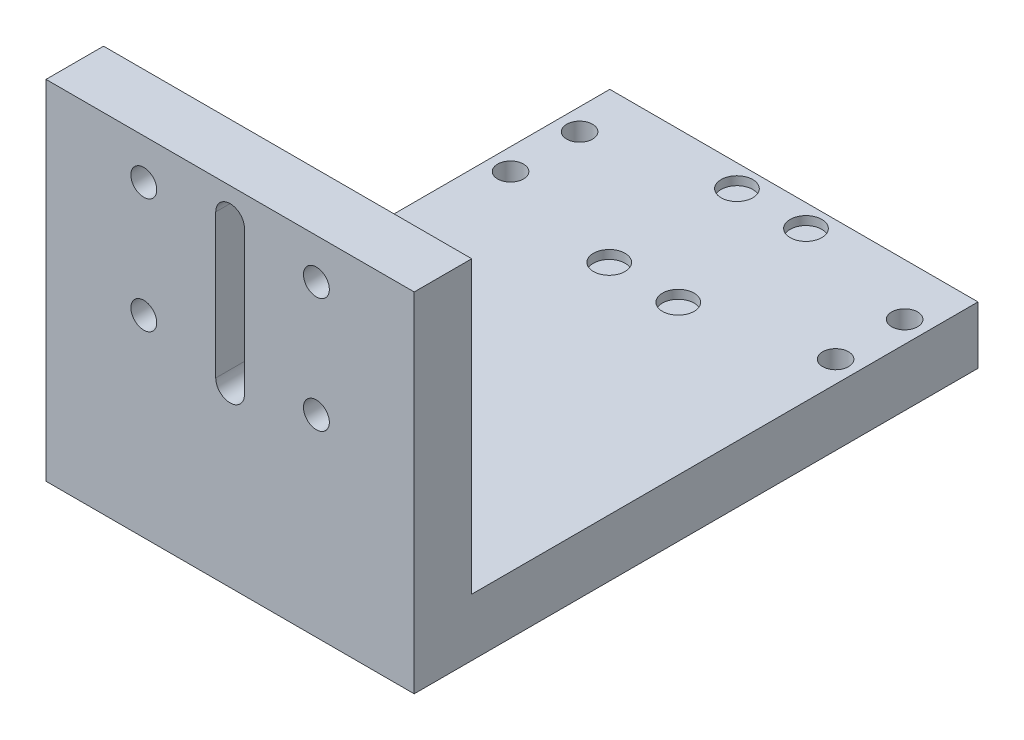
from build123d import *

# Parameters (mm, degrees)
BOSS_EXTRUDE1_DEPTH  = 64
SKETCH3_R            = 2.25
CUT_EXTRUDE1_DEPTH   = 10
LPATTERN1_COUNT      = 2
LPATTERN1_PITCH      = 30
LPATTERN1_COUNT_DIR2 = 2
LPATTERN1_PITCH_DIR2 = 20
SKETCH4_R            = 2.25
CUT_EXTRUDE2_DEPTH   = 10
LPATTERN2_COUNT      = 2
LPATTERN2_PITCH      = 12
LPATTERN2_COUNT_DIR2 = 2
LPATTERN2_PITCH_DIR2 = 56.5
CUT_EXTRUDE3_DEPTH   = 10
SKETCH6_R            = 2.75
CUT_EXTRUDE4_DEPTH   = 1.5
LPATTERN3_COUNT      = 2
LPATTERN3_PITCH      = 12
LPATTERN3_COUNT_DIR2 = 2
LPATTERN3_PITCH_DIR2 = 22.2


with BuildPart() as part:
    # Sketch1 → Boss-Extrude1 (new body)
    with BuildSketch(Plane(origin=(0, 0, 0), x_dir=(0, 0, -1), z_dir=(1, 0, 0))):
        Polygon((0, 60.5), (0, 0), (98, 0), (98, 10), (10, 10), (10, 60.5), align=None)
    extrude(amount=BOSS_EXTRUDE1_DEPTH)

    # Sketch3 → Cut-Extrude1 (cut)
    with BuildSketch(Plane(origin=(0, 0, -10), x_dir=(-1, 0, 0), z_dir=(0, 0, -1))):
        with Locations(Location((-47, 53.5, 0), (0, 0, 90))):  # turned: the seam where the file's is
            Circle(SKETCH3_R)
    cut_extrude1 = extrude(amount=-CUT_EXTRUDE1_DEPTH, mode=Mode.SUBTRACT)

    # LPattern1: Cut-Extrude1 2 × 2
    with Locations(*[(-i * LPATTERN1_PITCH, -j * LPATTERN1_PITCH_DIR2, 0) for i in range(LPATTERN1_COUNT) for j in range(LPATTERN1_COUNT_DIR2) if (i, j) != (0, 0)]):
        add(cut_extrude1, mode=Mode.SUBTRACT)

    # Sketch4 → Cut-Extrude2 (cut)
    with BuildSketch(Plane(origin=(0, 10, 0), x_dir=(1, 0, 0), z_dir=(0, 1, 0))):
        with Locations(Location((60.25, 89, 0), (0, 0, 270))):  # turned: the seam where the file's is
            Circle(SKETCH4_R)
    cut_extrude2 = extrude(amount=-CUT_EXTRUDE2_DEPTH, mode=Mode.SUBTRACT)

    # LPattern2: Cut-Extrude2 2 × 2
    with Locations(*[(-j * LPATTERN2_PITCH_DIR2, 0, i * LPATTERN2_PITCH) for i in range(LPATTERN2_COUNT) for j in range(LPATTERN2_COUNT_DIR2) if (i, j) != (0, 0)]):
        add(cut_extrude2, mode=Mode.SUBTRACT)

    # Sketch5 → Cut-Extrude3 (cut)
    with BuildSketch(Plane(origin=(0, 0, -10), x_dir=(-1, 0, 0), z_dir=(0, 0, -1))):
        with BuildLine():
            Line((-29.5, 55.3), (-29.5, 30.3))
            ThreePointArc((-29.5, 30.3), (-32, 27.8), (-34.5, 30.3))
            Line((-34.5, 30.3), (-34.5, 55.3))
            ThreePointArc((-34.5, 55.3), (-32, 57.8), (-29.5, 55.3))
        make_face()
    extrude(amount=-CUT_EXTRUDE3_DEPTH, mode=Mode.SUBTRACT)

    # Sketch6 → Cut-Extrude4 (cut)
    with BuildSketch(Plane(origin=(0, 10, 0), x_dir=(1, 0, 0), z_dir=(0, 1, 0))):
        with Locations(Location((38, 94.1, 0), (0, 0, 270))):  # turned: the seam where the file's is
            Circle(SKETCH6_R)
    cut_extrude4 = extrude(amount=-CUT_EXTRUDE4_DEPTH, mode=Mode.SUBTRACT)

    # LPattern3: Cut-Extrude4 2 × 2
    with Locations(*[(-i * LPATTERN3_PITCH, 0, j * LPATTERN3_PITCH_DIR2) for i in range(LPATTERN3_COUNT) for j in range(LPATTERN3_COUNT_DIR2) if (i, j) != (0, 0)]):
        add(cut_extrude4, mode=Mode.SUBTRACT)


solid = part.part
